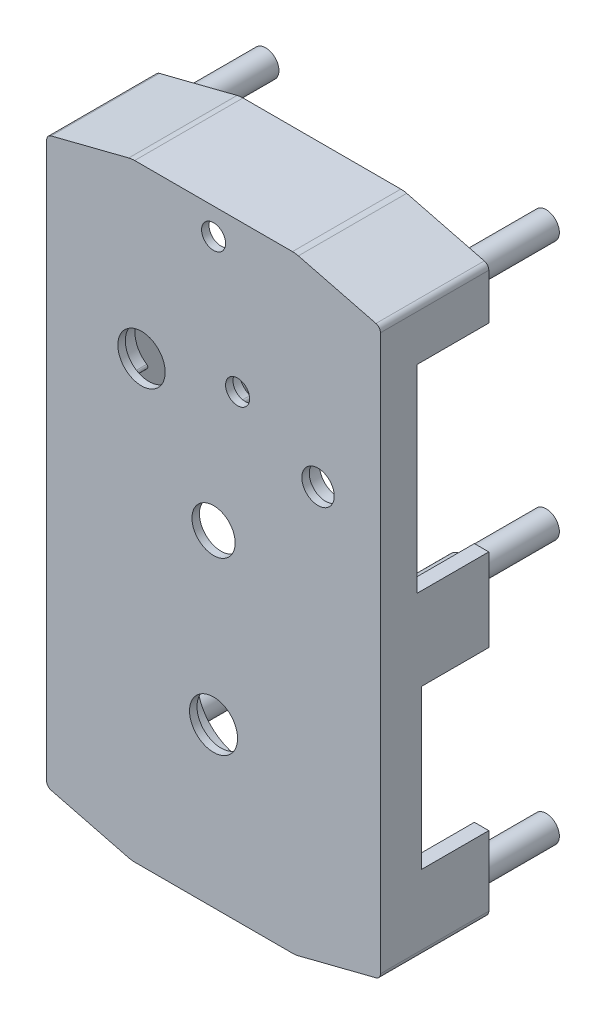
from build123d import *

# Parameters (mm, degrees)
BOSS_EXTRUDE1_DEPTH = 4.51
CUT_EXTRUDE1_DEPTH  = 4.2
SKETCH5_R           = 1
CUT_EXTRUDE2_DEPTH  = 4.1
SKETCH6_R           = 2
BOSS_EXTRUDE2_DEPTH = 1
SKETCH7_R           = 0.9
CUT_EXTRUDE3_DEPTH  = 1
SKETCH8_R           = 0.5
CUT_EXTRUDE4_DEPTH  = 1
SKETCH9_R           = 0.5
SKETCH9_R_2         = 0.985
SKETCH9_R_3         = 0.675
CUT_EXTRUDE5_DEPTH  = 1
SKETCH10_R          = 0.9
SKETCH10_R_2        = 0.75
BOSS_EXTRUDE3_DEPTH = 0.5
SKETCH11_W          = 3
SKETCH11_H          = 8.25
SKETCH11_W_2        = 2.8
SKETCH11_H_2        = 6.6
CUT_EXTRUDE6_DEPTH  = 0.6
SKETCH12_W          = 6.5
SKETCH12_H          = 2.5
CUT_EXTRUDE7_DEPTH  = 0.6
SKETCH15_W          = 2.5
SKETCH15_H          = 6.6
SKETCH15_W_2        = 2
SKETCH15_H_2        = 4
CUT_EXTRUDE8_DEPTH  = 0.6
SKETCH16_R          = 0.65
BOSS_EXTRUDE4_DEPTH = 4.2
SKETCH17_R          = 0.55
BOSS_EXTRUDE5_DEPTH = 3.5


with BuildPart() as part:
    # Sketch2 → Boss-Extrude1 (new body)
    with BuildSketch(Plane.XY):
        with BuildLine():
            ThreePointArc((-13.711599695, 0.852101617), (-13.847357447, 0.940933533), (-13.9, 1.09439375))
            Line((-13.9, 1.09439375), (-13.9, 24.20560625))
            ThreePointArc((-13.9, 24.20560625), (-13.847357447, 24.359066467), (-13.711599695, 24.447898383))
            Line((-13.711599695, 24.447898383), (-10.481270444, 25.269168531))
            ThreePointArc((-10.481270444, 25.269168531), (-10.359031781, 25.292262196), (-10.234871665, 25.3))
            Line((-10.234871665, 25.3), (-3.665128335, 25.3))
            ThreePointArc((-3.665128335, 25.3), (-3.540968219, 25.292262196), (-3.418729556, 25.269168531))
            Line((-3.418729556, 25.269168531), (-0.188400305, 24.447898383))
            ThreePointArc((-0.188400305, 24.447898383), (-0.052642553, 24.359066467), (0, 24.20560625))
            Line((0, 24.20560625), (0, 1.09439375))
            ThreePointArc((0, 1.09439375), (-0.052642553, 0.940933533), (-0.188400305, 0.852101617))
            Line((-0.188400305, 0.852101617), (-3.418729556, 0.030831469))
            ThreePointArc((-3.418729556, 0.030831469), (-3.540968219, 0.007737804), (-3.665128335, 0))
            Line((-3.665128335, 0), (-10.234871665, 0))
            ThreePointArc((-10.234871665, 0), (-10.359031781, 0.007737804), (-10.481270444, 0.030831469))
            Line((-10.481270444, 0.030831469), (-13.711599695, 0.852101617))
        make_face()
    extrude(amount=BOSS_EXTRUDE1_DEPTH)

    # Sketch4 → Cut-Extrude1 (cut)
    with BuildSketch(Plane(origin=(0, 0, 0), x_dir=(-1, 0, 0), z_dir=(0, 0, -1))):
        with BuildLine():
            Line((13.3, 1.366545), (13.3, 23.933455))
            Line((13.3, 23.933455), (10.333431177, 24.687667412))
            ThreePointArc((10.333431177, 24.687667412), (10.284535712, 24.696904878), (10.234871665, 24.7))
            Line((10.234871665, 24.7), (3.665128335, 24.7))
            ThreePointArc((3.665128335, 24.7), (3.615464288, 24.696904878), (3.566568823, 24.687667412))
            Line((3.566568823, 24.687667412), (0.6, 23.933455))
            Line((0.6, 23.933455), (0.6, 1.366545))
            Line((0.6, 1.366545), (3.566568823, 0.612332588))
            ThreePointArc((3.566568823, 0.612332588), (3.615464288, 0.603095122), (3.665128335, 0.6))
            Line((3.665128335, 0.6), (10.234871665, 0.6))
            ThreePointArc((10.234871665, 0.6), (10.284535712, 0.603095122), (10.333431177, 0.612332588))
            Line((10.333431177, 0.612332588), (13.3, 1.366545))
        make_face()
    extrude(amount=-CUT_EXTRUDE1_DEPTH, mode=Mode.SUBTRACT)

    # Sketch5 → Cut-Extrude2 (cut)
    with BuildSketch(Plane(origin=(0, 0, 4.2), x_dir=(-1, 0, 0), z_dir=(0, 0, -1))):
        with Locations((6.95, 6.6)):
            Circle(SKETCH5_R)
    extrude(amount=-CUT_EXTRUDE2_DEPTH, mode=Mode.SUBTRACT)

    # Sketch6 → Boss-Extrude2 (add)
    with BuildSketch(Plane(origin=(0, 0, 4.2), x_dir=(-1, 0, 0), z_dir=(0, 0, -1))):
        with BuildLine():
            Line((10.333431177, 0.612332588), (7.641436182, 4.197518781))
            ThreePointArc((7.641436182, 4.197518781), (9.050983212, 5.245057365), (9.423767329, 6.961213511))
            Line((9.423767329, 6.961213511), (13.3, 8.366545))
            Line((13.3, 8.366545), (13.3, 8.898391577))
            Line((13.3, 8.898391577), (9.301519142, 7.448738903))
            ThreePointArc((9.301519142, 7.448738903), (6.95, 9.1), (4.598480858, 7.448738903))
            Line((4.598480858, 7.448738903), (0.6, 8.898391577))
            Line((0.6, 8.898391577), (0.6, 8.366545))
            Line((0.6, 8.366545), (4.476232671, 6.961213511))
            ThreePointArc((4.476232671, 6.961213511), (4.849016788, 5.245057365), (6.258563818, 4.197518781))
            Line((6.258563818, 4.197518781), (3.566568823, 0.612332588))
            ThreePointArc((3.566568823, 0.612332588), (3.615464288, 0.603095122), (3.665128335, 0.6))
            Line((3.665128335, 0.6), (4.182568645, 0.6))
            Line((4.182568645, 0.6), (6.813404294, 4.103734467))
            ThreePointArc((6.813404294, 4.103734467), (6.95, 4.1), (7.086595706, 4.103734467))
            Line((7.086595706, 4.103734467), (9.717431355, 0.6))
            Line((9.717431355, 0.6), (10.234871665, 0.6))
            ThreePointArc((10.234871665, 0.6), (10.284535712, 0.603095122), (10.333431177, 0.612332588))
        make_face()
        with Locations((6.95, 6.6)):
            Circle(SKETCH6_R, mode=Mode.SUBTRACT)
    extrude(amount=BOSS_EXTRUDE2_DEPTH)

    # Sketch7 → Cut-Extrude3 (cut)
    with BuildSketch(Plane(origin=(0, 0, 4.2), x_dir=(-1, 0, 0), z_dir=(0, 0, -1))):
        with Locations((6.95, 13.6)):
            Circle(SKETCH7_R)
    extrude(amount=-CUT_EXTRUDE3_DEPTH, mode=Mode.SUBTRACT)

    # Sketch8 → Cut-Extrude4 (cut)
    with BuildSketch(Plane(origin=(0, 0, 4.2), x_dir=(-1, 0, 0), z_dir=(0, 0, -1))):
        with Locations(Location((6.95, 24.2, 0), (0, 0, 90))):
            Circle(SKETCH8_R)
    extrude(amount=-CUT_EXTRUDE4_DEPTH, mode=Mode.SUBTRACT)

    # Sketch9 → Cut-Extrude5 (cut)
    with BuildSketch(Plane(origin=(0, 0, 4.2), x_dir=(-1, 0, 0), z_dir=(0, 0, -1))):
        with Locations((5.95, 19.1)):
            Circle(SKETCH9_R)
        with Locations((9.95, 18.3)):
            Circle(SKETCH9_R_2)
        with Locations((2.6, 17.35)):
            Circle(SKETCH9_R_3)
    extrude(amount=-CUT_EXTRUDE5_DEPTH, mode=Mode.SUBTRACT)

    # Sketch10 → Boss-Extrude3 (add)
    with BuildSketch(Plane(origin=(0, 0, 4.2), x_dir=(-1, 0, 0), z_dir=(0, 0, -1))):
        with Locations((2.6, 17.35)):
            Circle(SKETCH10_R)
        with Locations((2.6, 17.35)):
            Circle(SKETCH10_R_2, mode=Mode.SUBTRACT)
        with BuildLine():
            ThreePointArc((6.348411752, 18.18279333), (6.008413842, 20.098292454), (5.447334993, 18.235518716))
            ThreePointArc((5.447334993, 18.235518716), (5.618228279, 18.28074575), (5.573001245, 18.451639037))
            ThreePointArc((5.573001245, 18.451639037), (5.993810381, 19.84871934), (6.248808814, 18.412094997))
            ThreePointArc((6.248808814, 18.412094997), (6.183959449, 18.247642694), (6.348411752, 18.18279333))
        make_face()
        with BuildLine():
            ThreePointArc((10.652922784, 17.227125511), (10.778596901, 19.279074709), (8.775669457, 18.815856457))
            ThreePointArc((8.775669457, 18.815856457), (8.827006943, 18.684082171), (8.95878123, 18.735419658))
            ThreePointArc((8.95878123, 18.735419658), (10.649394907, 19.126408914), (10.543316985, 17.394417378))
            ThreePointArc((10.543316985, 17.394417378), (10.514473951, 17.255968545), (10.652922784, 17.227125511))
        make_face()
    extrude(amount=BOSS_EXTRUDE3_DEPTH)

    # Sketch11 → Cut-Extrude6 (cut)
    with BuildSketch(Plane(origin=(0, 0, 0), x_dir=(0, 0, -1), z_dir=(1, 0, 0))):
        with Locations((-1.5, 18.175)):
            Rectangle(SKETCH11_W, SKETCH11_H)
        with Locations((-1.4, 7.3)):
            Rectangle(SKETCH11_W_2, SKETCH11_H_2)
    extrude(amount=-CUT_EXTRUDE6_DEPTH, mode=Mode.SUBTRACT)

    # Sketch12 → Cut-Extrude7 (cut)
    with BuildSketch(Plane.XZ):
        with Locations((-6.95, 1.25)):
            Rectangle(SKETCH12_W, SKETCH12_H)
    extrude(amount=-CUT_EXTRUDE7_DEPTH, mode=Mode.SUBTRACT)

    # Sketch15 → Cut-Extrude8 (cut)
    with BuildSketch(Plane.ZY.offset(13.9)):
        with Locations((1.25, 7.3)):
            Rectangle(SKETCH15_W, SKETCH15_H)
        with Locations((1, 20)):
            Rectangle(SKETCH15_W_2, SKETCH15_H_2)
    extrude(amount=-CUT_EXTRUDE8_DEPTH, mode=Mode.SUBTRACT)

    # Sketch16 → Boss-Extrude4 (add)
    with BuildSketch(Plane(origin=(0, 0, 4.2), x_dir=(-1, 0, 0), z_dir=(0, 0, -1))):
        with Locations((1.112347538, 23.533455)):
            Circle(SKETCH16_R)
        with Locations((1.112347538, 12.75)):
            Circle(SKETCH16_R)
        with Locations((1.112347538, 1.766545)):
            Circle(SKETCH16_R)
        with Locations((12.787652462, 1.766545)):
            Circle(SKETCH16_R)
        with Locations((12.787652462, 12.75)):
            Circle(SKETCH16_R)
        with Locations((12.787652462, 23.533455)):
            Circle(SKETCH16_R)
    extrude(amount=BOSS_EXTRUDE4_DEPTH)

    # Sketch17 → Boss-Extrude5 (add)
    with BuildSketch(Plane(origin=(0, 0, 0), x_dir=(-1, 0, 0), z_dir=(0, 0, -1))):
        with Locations(Location((1.112347538, 12.75, 0), (0, 0, 180))):
            Circle(SKETCH17_R)
        with Locations(Location((1.112347538, 23.533455, 0), (0, 0, 180))):
            Circle(SKETCH17_R)
        with Locations(Location((1.112347538, 1.766545, 0), (0, 0, 180))):
            Circle(SKETCH17_R)
        with Locations(Location((12.787652462, 1.766545, 0), (0, 0, 180))):
            Circle(SKETCH17_R)
        with Locations(Location((12.787652462, 12.75, 0), (0, 0, 180))):
            Circle(SKETCH17_R)
        with Locations(Location((12.787652462, 23.533455, 0), (0, 0, 180))):
            Circle(SKETCH17_R)
    extrude(amount=BOSS_EXTRUDE5_DEPTH)


solid = part.part
